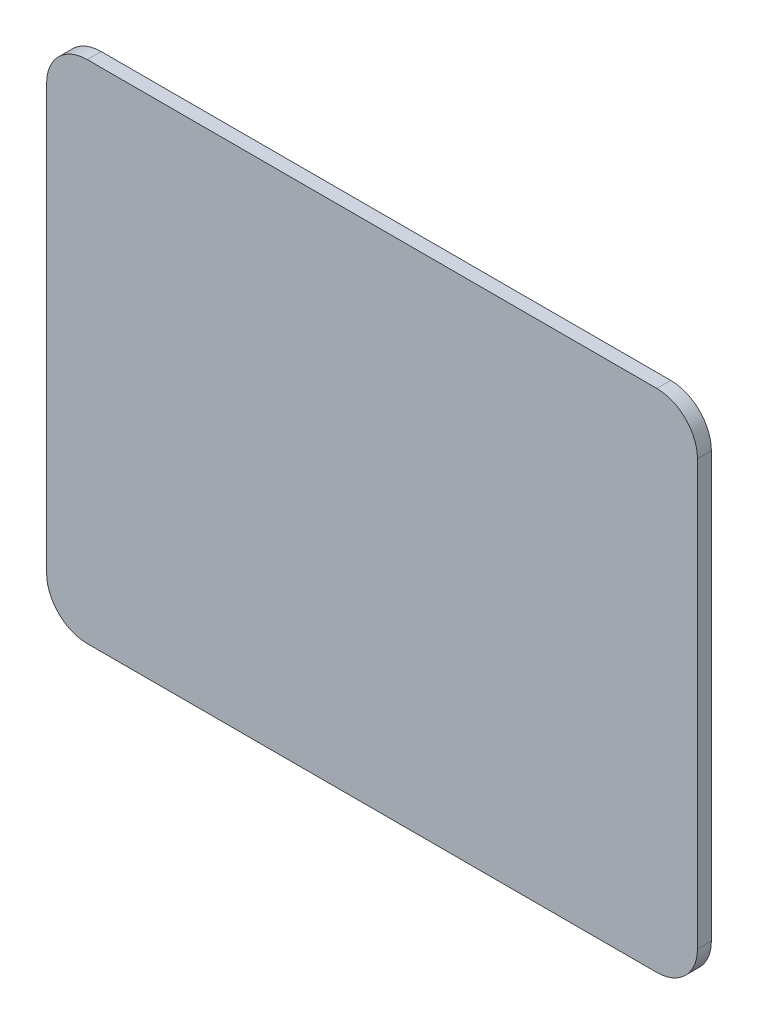
from build123d import *

# Parameters (mm, degrees)
SKETCH1_W           = 112.2
SKETCH1_H           = 87.2
BOSS_EXTRUDE1_DEPTH = 2.4
FILLET2_R           = 7


with BuildPart() as part:
    # Sketch1 → Boss-Extrude1 (new body)
    with BuildSketch(Plane.XY):
        with Locations((-36.763518847, -18.340032361)):
            Rectangle(SKETCH1_W, SKETCH1_H)
    extrude(amount=BOSS_EXTRUDE1_DEPTH)

    # Fillet2
    fillet2_edges = [part.edges().sort_by_distance(p)[0] for p in [
        (-92.863518847, 25.259967639, 1.2),
        (19.336481153, 25.259967639, 1.2),
        (19.336481153, -61.940032361, 1.2),
        (-92.863518847, -61.940032361, 1.2),
    ]]
    fillet(fillet2_edges, radius=FILLET2_R)


solid = part.part
